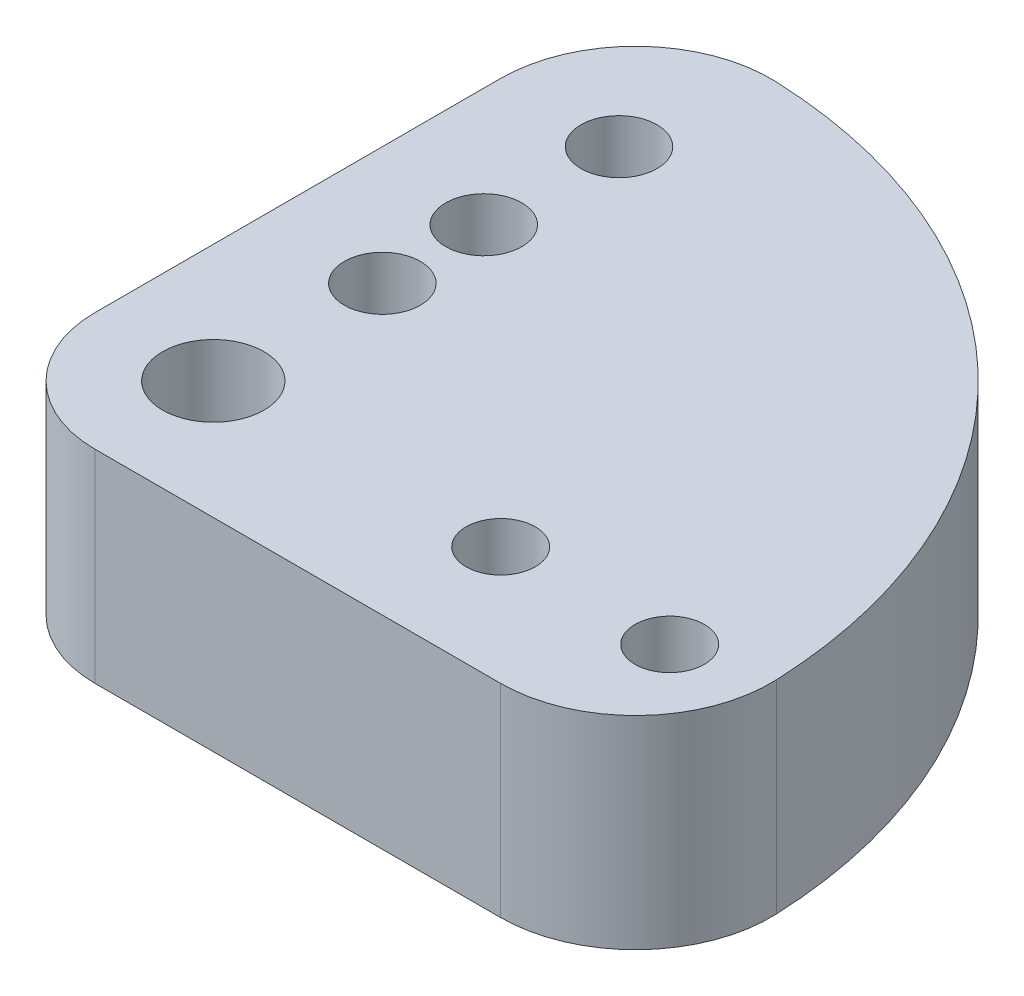
from build123d import *

# Parameters (mm, degrees)
SKETCH_1_R          = 1.025
SKETCH_1_R_2        = 1.5
SKETCH_1_R_3        = 1.125
EXTRUDE_1_DEPTH     = 6
SKETCH_3_R          = 2.5
CUT_EXTRUDE_1_DEPTH = 3
FILLET_1_R          = 4


with BuildPart() as part:
    # 草图1 → 凸台-拉伸1 (new body)
    with BuildSketch(Plane(origin=(0, 0, 0), x_dir=(1, 0, 0), z_dir=(0, 1, 0))):
        with BuildLine():
            Line((0, -3.5), (15.612494996, -3.5))
            ThreePointArc((15.612494996, -3.5), (11.313708499, 11.313708499), (-3.5, 15.612494996))
            Line((-3.5, 15.612494996), (-3.5, 0))
            ThreePointArc((-3.5, 0), (-2.474873734, -2.474873734), (0, -3.5))
        make_face()
        with Locations((8.5, 0)):
            Circle(SKETCH_1_R, mode=Mode.SUBTRACT)
        with Locations((13.5, 0)):
            Circle(SKETCH_1_R, mode=Mode.SUBTRACT)
        Circle(SKETCH_1_R_2, mode=Mode.SUBTRACT)
        with Locations((0, 12)):
            Circle(SKETCH_1_R_3, mode=Mode.SUBTRACT)
        with Locations((0, 8)):
            Circle(SKETCH_1_R_3, mode=Mode.SUBTRACT)
        with Locations((0, 5)):
            Circle(SKETCH_1_R_3, mode=Mode.SUBTRACT)
    extrude(amount=EXTRUDE_1_DEPTH)

    # 草图3 → 切除-拉伸1 (cut)
    with BuildSketch(Plane.XZ):
        Circle(SKETCH_3_R)
    extrude(amount=-CUT_EXTRUDE_1_DEPTH, mode=Mode.SUBTRACT)

    # 圆角1
    fillet_1_edges = [part.edges().sort_by_distance(p)[0] for p in [
        (15.612494996, 3, 3.5),
        (-3.5, 3, -15.612494996),
    ]]
    fillet(fillet_1_edges, radius=FILLET_1_R)


solid = part.part
